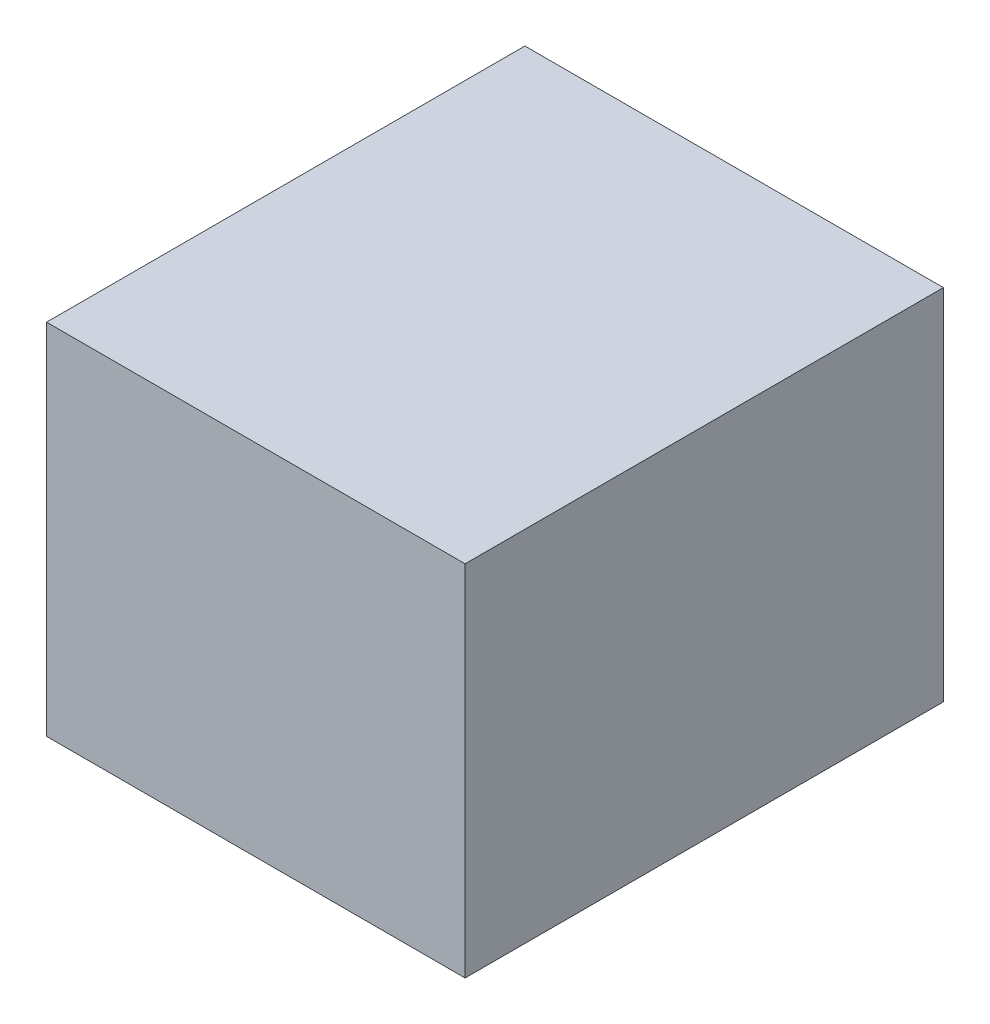
from build123d import *

# Parameters (mm, degrees)
SKETCH1_W           = 711.2
SKETCH1_H           = 812.8
BOSS_EXTRUDE1_DEPTH = 304.8


with BuildPart() as part:
    # Sketch1 → Boss-Extrude1 (new body, symmetric)
    with BuildSketch(Plane(origin=(0, 0, 0), x_dir=(1, 0, 0), z_dir=(0, 1, 0))):
        Rectangle(SKETCH1_W, SKETCH1_H)
    extrude(amount=BOSS_EXTRUDE1_DEPTH, both=True)


solid = part.part
